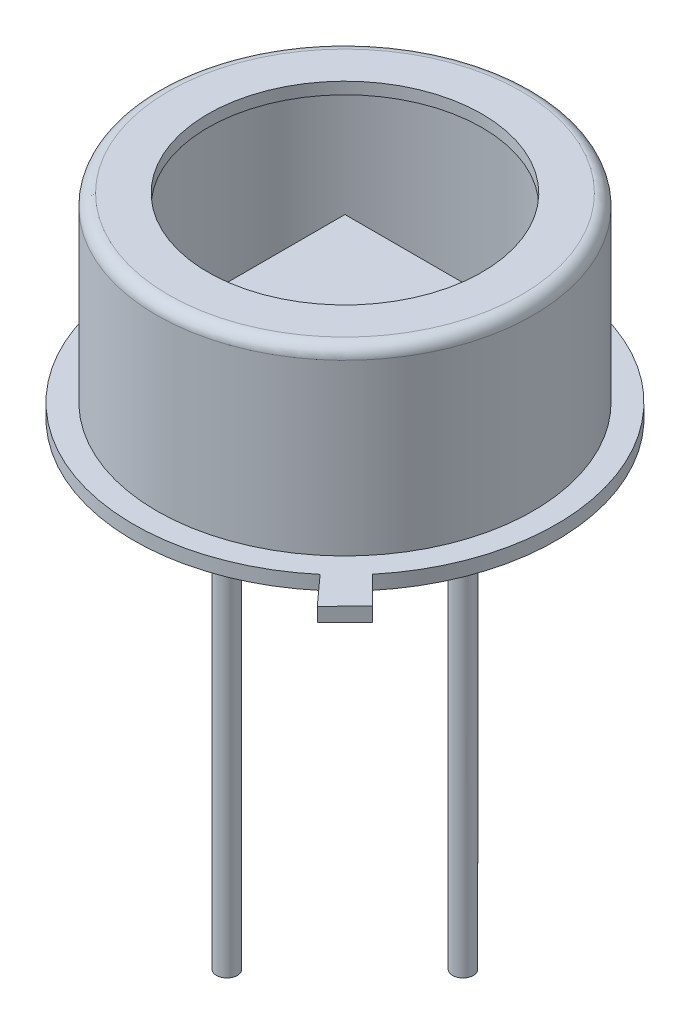
from build123d import *

# Parameters (mm, degrees)
SKETCH2_R           = 4.55
BOSS_EXTRUDE1_DEPTH = 0.046
BOSS_EXTRUDE2_START = -2.3
SKETCH3_W           = 3
SKETCH3_H           = 3
BOSS_EXTRUDE2_DEPTH = 0.508
BOSS_EXTRUDE3_DEPTH = 0.3
SKETCH5_R           = 0.225
BOSS_EXTRUDE4_DEPTH = 9
SKETCH7_R           = 0.75
BOSS_EXTRUDE5_DEPTH = 0.4


with BuildPart() as part:
    # Sketch1 → Revolve-Thin2 (revolve)
    with BuildSketch(Plane.XY, mode=Mode.PRIVATE) as revolve_thin2_sk:
        with BuildLine():
            Line((4.55, 0), (4.55, 0.3))
            Line((4.55, 0.3), (4.05, 0.3))
            Line((4.05, 0.3), (4.05, 3.946))
            ThreePointArc((4.05, 3.946), (3.975605122, 4.125605122), (3.796, 4.2))
            Line((3.796, 4.2), (2.95, 4.2))
            Line((2.95, 4.2), (2.95, 3.946))
            Line((2.95, 3.946), (3.796, 3.946))
            Line((3.796, 3.946), (3.796, 0.046))
            Line((3.796, 0.046), (4.296, 0.046))
            Line((4.296, 0.046), (4.296, 0))
            Line((4.296, 0), (4.55, 0))
        make_face()
    revolve(revolve_thin2_sk.sketch.rotate(Axis((0, 0, 0), (0, 1, 0)), 90), axis=Axis((0, 0, 0), (0, 1, 0)))  # turned: the seam where the file's is

    # Sketch2 → Boss-Extrude1 (add)
    with BuildSketch(Plane.XZ):
        with Locations(Location((0, 0, 0), (0, 0, 270))):  # turned: the seam where the file's is
            Circle(SKETCH2_R)
    extrude(amount=-BOSS_EXTRUDE1_DEPTH)

    # Sketch4 → Boss-Extrude3 (add)
    with BuildSketch(Plane.XZ):
        Polygon((3.499150564, 2.908340649), (2.938865798, 3.473552623), (3.503435617, 4.099455918), (4.096846657, 3.500826355), align=None)
    extrude(amount=-BOSS_EXTRUDE3_DEPTH)

    # Sketch5 → Boss-Extrude4 (add)
    with BuildSketch(Plane.XZ):
        with Locations(Location((-2.54, 0, 0), (0, 0, 90))):  # turned: the seam where the file's is
            Circle(SKETCH5_R)
        with Locations(Location((2.54, 0, 0), (0, 0, 90))):  # turned: the seam where the file's is
            Circle(SKETCH5_R)
        with Locations(Location((0, 2.54, 0), (0, 0, 90))):  # turned: the seam where the file's is
            Circle(SKETCH5_R)
    extrude(amount=BOSS_EXTRUDE4_DEPTH)

    # Sketch7 → Boss-Extrude5 (add)
    with BuildSketch(Plane.XZ):
        with Locations(Location((0, 2.54, 0), (0, 0, 90))):  # turned: the seam where the file's is
            Circle(SKETCH7_R)
    extrude(amount=BOSS_EXTRUDE5_DEPTH)


with BuildPart() as body_2:
    # Sketch3 → Boss-Extrude2 (new body)
    with BuildSketch(Plane.XZ.offset(BOSS_EXTRUDE2_START)):
        Rectangle(SKETCH3_W, SKETCH3_H)
    extrude(amount=BOSS_EXTRUDE2_DEPTH)


solid = Compound([part.part, body_2.part])
